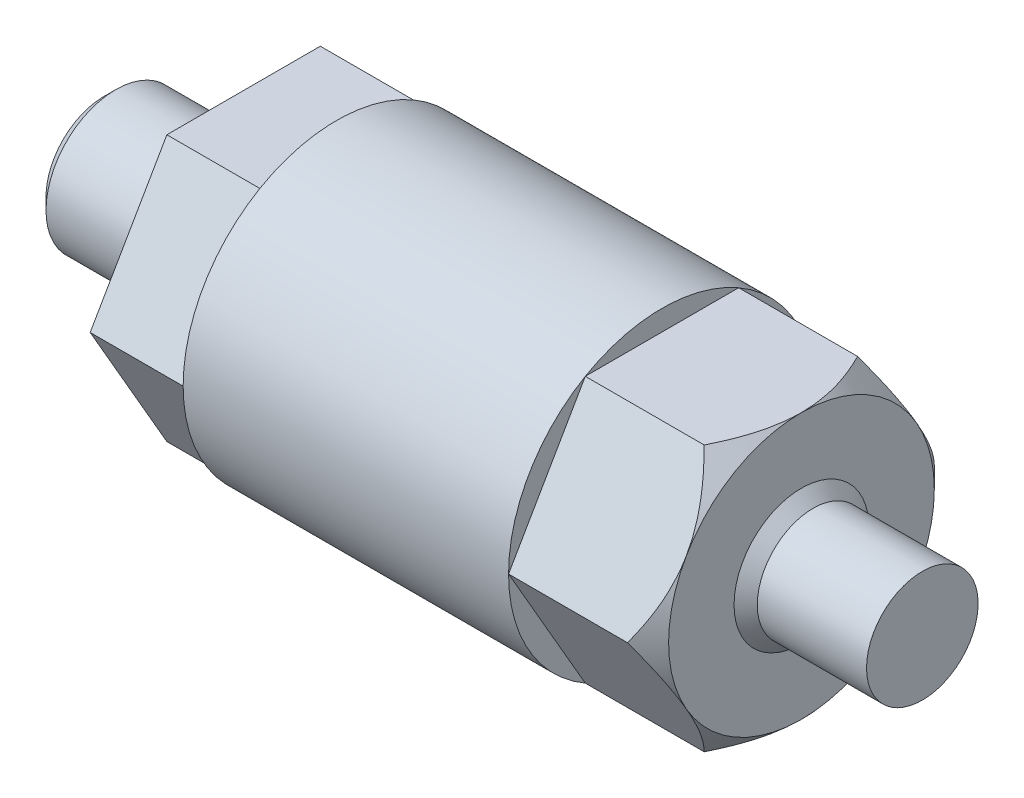
from build123d import *

# Parameters (mm, degrees)
SKETCH2_OUTSIDE_W  = 23.168
SKETCH2_OUTSIDE_H  = 23.168
CUT_EXTRUDE1_DEPTH = 6
SKETCH3_OUTSIDE_W  = 23.168
SKETCH3_OUTSIDE_H  = 23.168
CUT_EXTRUDE2_DEPTH = 4
CHAMFER1_SIZE      = 0.5


with BuildPart() as part:
    # Sketch1 → Revolve1 (revolve)
    with BuildSketch(Plane(origin=(0, 0, 0), x_dir=(1, 0, 0), z_dir=(0, 1, 0))):
        Polygon((0, 6.6), (0, 3), (-6, 3), (-6, 0), (29.2, 0), (29.2, 2.4), (24, 2.4), (24, 6.6), align=None)
    revolve(axis=Axis((-26.186440678, 0, 0), (1, 0, 0)))

    # Sketch2 outside → Cut-Extrude1 (cut)
    with BuildSketch(Plane(origin=(24, 0, 0), x_dir=(0, 0, -1), z_dir=(1, 0, 0))):
        Rectangle(SKETCH2_OUTSIDE_W, SKETCH2_OUTSIDE_H)
        Polygon((3.3, -5.715767665), (6.6, 0), (3.3, 5.715767665), (-3.3, 5.715767665), (-6.6, 0), (-3.3, -5.715767665), align=None, mode=Mode.SUBTRACT)
    extrude(amount=-CUT_EXTRUDE1_DEPTH, mode=Mode.SUBTRACT)

    # Sketch3 outside → Cut-Extrude2 (cut)
    with BuildSketch(Plane.ZY):
        Rectangle(SKETCH3_OUTSIDE_W, SKETCH3_OUTSIDE_H)
        Polygon((3.3, -5.715767665), (6.6, 0), (3.3, 5.715767665), (-3.3, 5.715767665), (-6.6, 0), (-3.3, -5.715767665), align=None, mode=Mode.SUBTRACT)
    extrude(amount=-CUT_EXTRUDE2_DEPTH, mode=Mode.SUBTRACT)

    # Sketch4 → Cut-Revolve1 (revolve, cut)
    with BuildSketch(Plane.XY):
        Polygon((22.019646918, 7.696120747), (25.980353082, 3.735414583), (25.980353082, 7.696120747), align=None)
    revolve(axis=Axis((-26.186440678, 0, 0), (1, 0, 0)), mode=Mode.SUBTRACT)

    # Chamfer1
    chamfer1_edges = [part.edges().sort_by_distance(p)[0] for p in [
        (24, 0, 2.4),
        (-6, 0, 3),
    ]]
    chamfer(chamfer1_edges, length=CHAMFER1_SIZE)


solid = part.part
